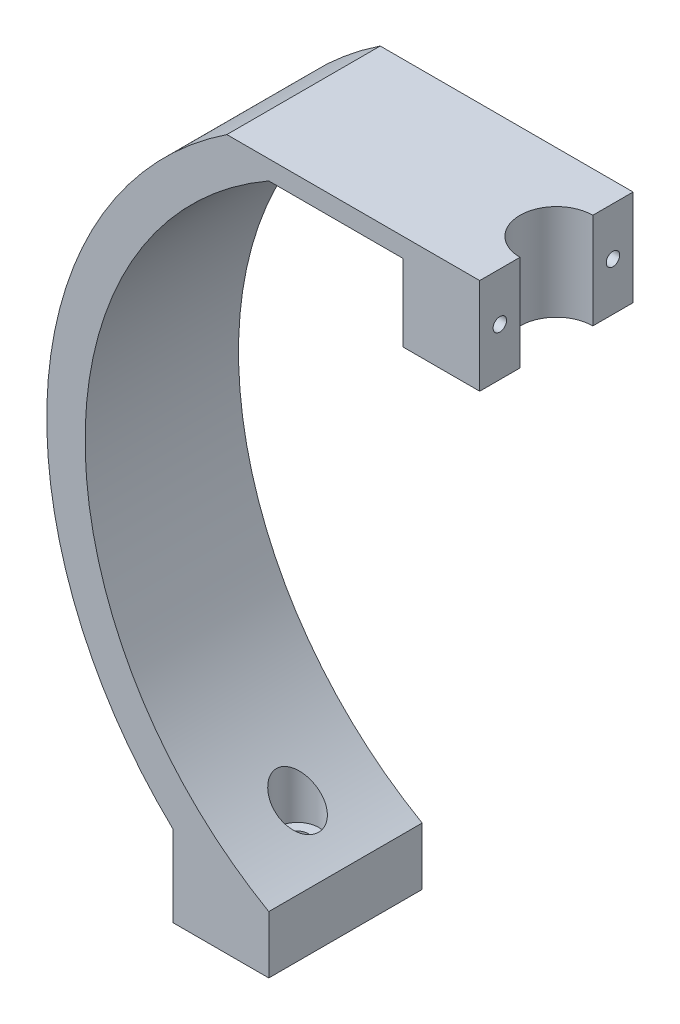
from build123d import *

# Parameters (mm, degrees)
BOSS_EXTRUDE1_DEPTH = 40
SKETCH2_R           = 9.5
CUT_EXTRUDE1_DEPTH  = 186
SKETCH3_R           = 2.75
CUT_EXTRUDE2_DEPTH  = 40
CUT_EXTRUDE3_START  = -15
SKETCH4_R           = 5.5
CUT_EXTRUDE3_DEPTH  = 29
SKETCH5_R           = 1.75
CUT_EXTRUDE4_DEPTH  = 31


with BuildPart() as part:
    # Sketch1 → Boss-Extrude1 (new body)
    with BuildSketch(Plane.XY):
        with BuildLine():
            ThreePointArc((0, 180), (-47.896390796, 97.5), (0, 15))
            Line((0, 15), (0, 0))
            Line((0, 0), (-25, 0))
            Line((-25, 0), (-25, 21.171305921))
            ThreePointArc((-25, 21.171305921), (-57.511689732, 106.47993478), (-10.937324628, 185))
            Line((-10.937324628, 185), (55, 185))
            Line((55, 185), (55, 160))
            Line((55, 160), (35, 160))
            Line((35, 160), (35, 180))
            Line((35, 180), (0, 180))
        make_face()
    extrude(amount=BOSS_EXTRUDE1_DEPTH)

    # Sketch2 → Cut-Extrude1 (cut, through all)
    with BuildSketch(Plane(origin=(0, 185, 0), x_dir=(1, 0, 0), z_dir=(0, 1, 0))):
        with Locations((55, -20)):
            Circle(SKETCH2_R)
    extrude(amount=-CUT_EXTRUDE1_DEPTH, mode=Mode.SUBTRACT)

    # Sketch3 → Cut-Extrude2 (cut)
    with BuildSketch(Plane.XZ):
        with Locations((-12.5, 20)):
            Circle(SKETCH3_R)
    extrude(amount=-CUT_EXTRUDE2_DEPTH, mode=Mode.SUBTRACT)

    # Sketch4 → Cut-Extrude3 (cut)
    with BuildSketch(Plane.XZ.offset(CUT_EXTRUDE3_START)):
        with Locations((-12.5, 20)):
            Circle(SKETCH4_R)
    extrude(amount=-CUT_EXTRUDE3_DEPTH, mode=Mode.SUBTRACT)

    # Sketch5 → Cut-Extrude4 (cut)
    with BuildSketch(Plane(origin=(55, 0, 0), x_dir=(0, 0, -1), z_dir=(1, 0, 0))):
        with Locations((-5.25, 172.5)):
            Circle(SKETCH5_R)
        with Locations((-34.75, 172.5)):
            Circle(SKETCH5_R)
    extrude(amount=-CUT_EXTRUDE4_DEPTH, mode=Mode.SUBTRACT)


solid = part.part
